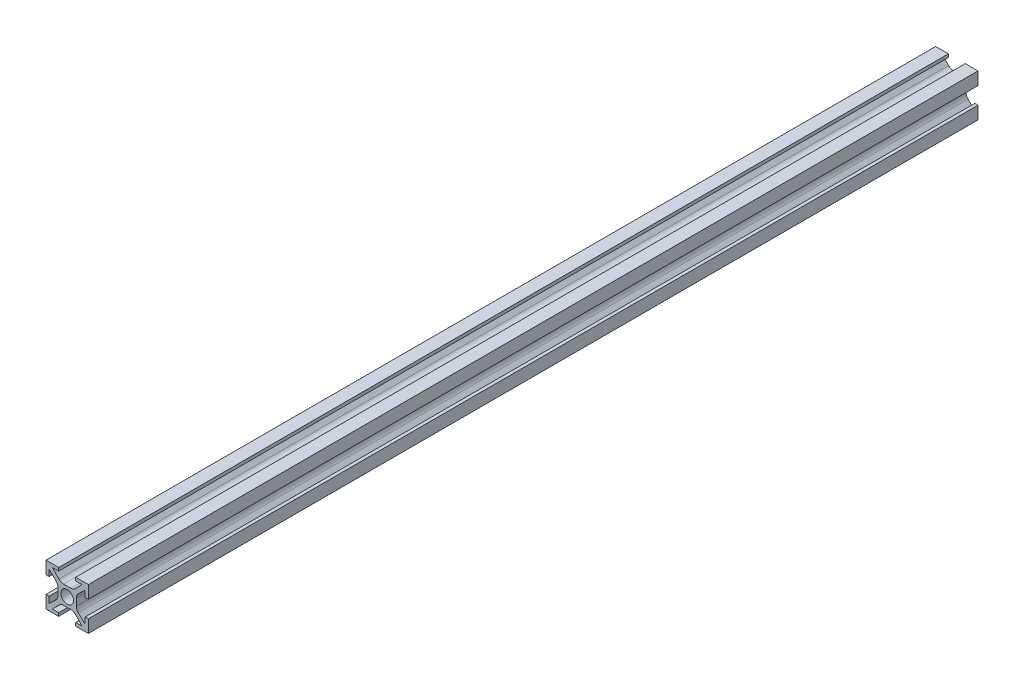
from build123d import *

# Parameters (mm, degrees)
ESBO_O1_W                  = 20
ESBO_O1_H                  = 20
RESSALTO_EXTRUS_O1_DEPTH   = 420
ESBO_O2_R                  = 3
CORTE_EXTRUS_O1_DEPTH      = 1
CORTE_EXTRUS_O1_DEPTH_BACK = 421
FILETE1_R                  = 3


with BuildPart() as part:
    # Esboço1 → Ressalto-extrusão1 (new body)
    with BuildSketch(Plane.XY):
        Rectangle(ESBO_O1_W, ESBO_O1_H)
    extrude(amount=RESSALTO_EXTRUS_O1_DEPTH)

    # Esboço2 → Corte-extrusão1 (cut, two sides)
    with BuildSketch(Plane(origin=(0, 0, 0), x_dir=(-1, 0, 0), z_dir=(0, 0, -1))) as corte_extrus_o1_sk:
        Circle(ESBO_O2_R)
        Polygon((-10, 4), (-8.5, 4), (-8.5, 7), (-4.353828188, 3), (-4.353828188, -3), (-8.5, -7), (-8.5, -4), (-10, -4), align=None)
        Polygon((4, 10), (4, 8.5), (7, 8.5), (3, 4.353828188), (-3, 4.353828188), (-7, 8.5), (-4, 8.5), (-4, 10), align=None)
        Polygon((10, -4), (8.5, -4), (8.5, -7), (4.353828188, -3), (4.353828188, 3), (8.5, 7), (8.5, 4), (10, 4), align=None)
        Polygon((-4, -10), (-4, -8.5), (-7, -8.5), (-3, -4.353828188), (3, -4.353828188), (7, -8.5), (4, -8.5), (4, -10), align=None)
    extrude(amount=CORTE_EXTRUS_O1_DEPTH, mode=Mode.SUBTRACT)
    extrude(corte_extrus_o1_sk.sketch, amount=-CORTE_EXTRUS_O1_DEPTH_BACK, mode=Mode.SUBTRACT)

    # Filete1
    filete1_edges = [part.edges().sort_by_distance(p)[0] for p in [
        (-3, 4.353828188, 210),
        (3, 4.353828188, 210),
        (4.353828188, 3, 210),
        (4.353828188, -3, 210),
        (3, -4.353828188, 210),
        (-3, -4.353828188, 210),
        (-4.353828188, -3, 210),
        (-4.353828188, 3, 210),
    ]]
    fillet(filete1_edges, radius=FILETE1_R)


solid = part.part
